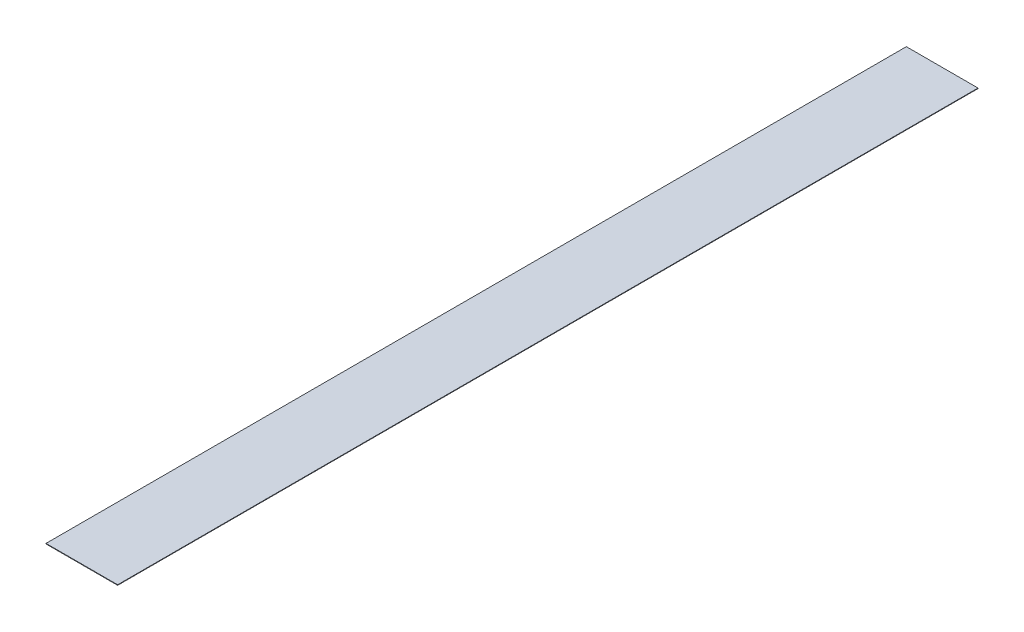
from build123d import *

# Parameters (mm, degrees)
SKETCH1_W      = 24.9
SKETCH1_H      = 299
EXTRUDE1_DEPTH = 0.175


with BuildPart() as part:
    # Sketch1 → Extrude1 (new body)
    with BuildSketch(Plane(origin=(0, 0, 0), x_dir=(1, 0, 0), z_dir=(0, 1, 0))):
        Rectangle(SKETCH1_W, SKETCH1_H)
    extrude(amount=EXTRUDE1_DEPTH)


solid = part.part
